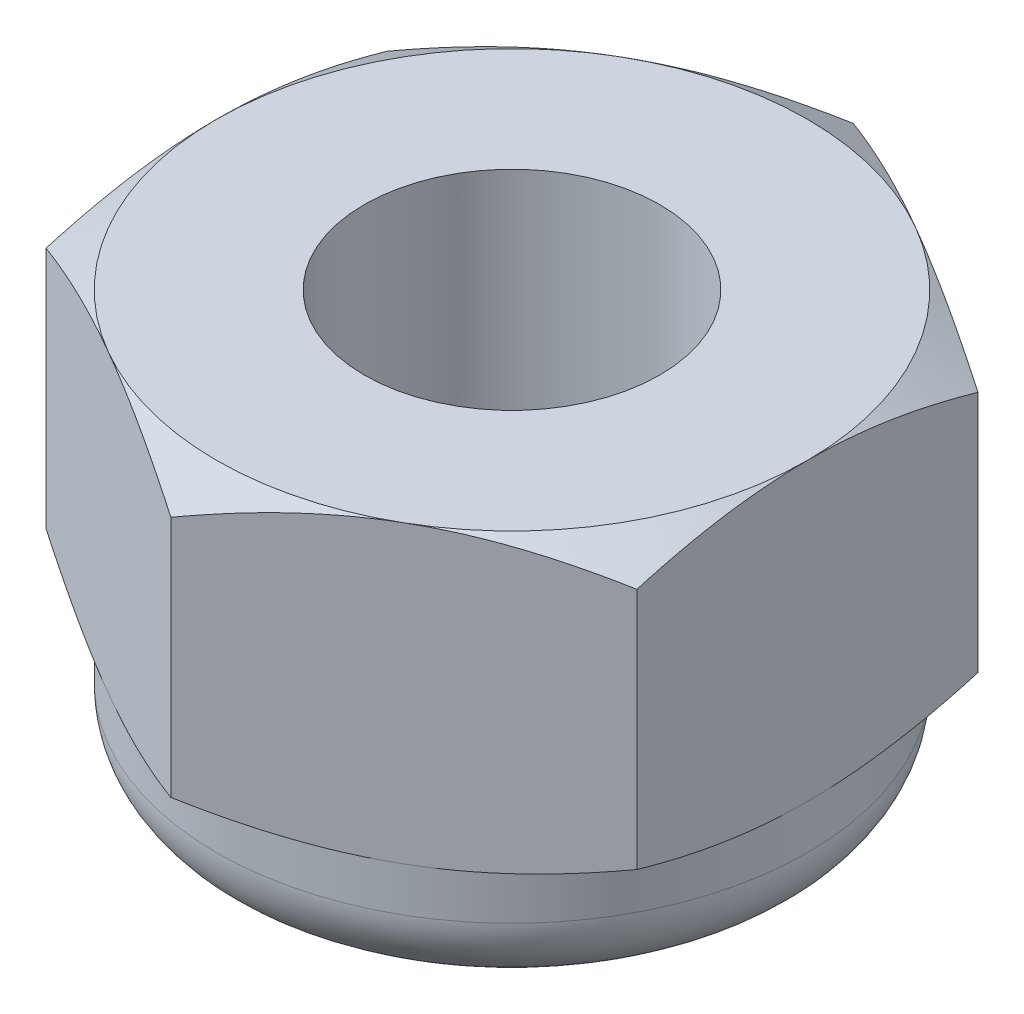
from build123d import *

# Parameters (mm, degrees)
SKETCH_1_R      = 1
EXTRUDE_2_DEPTH = 2
SKETCH_3_R      = 2
SKETCH_3_R_2    = 1
EXTRUDE_3_DEPTH = 0.8
FILLET_1_R      = 0.5


with BuildPart() as part:
    # 草图1 → 凸台-拉伸2 (new body)
    with BuildSketch(Plane(origin=(0, 0, 0), x_dir=(1, 0, 0), z_dir=(0, 1, 0))):
        Polygon((2, 1.154700538), (0, 2.309401077), (-2, 1.154700538), (-2, -1.154700538), (0, -2.309401077), (2, -1.154700538), align=None)
        Circle(SKETCH_1_R, mode=Mode.SUBTRACT)
    extrude(amount=EXTRUDE_2_DEPTH)

    # 草图2 → 切除-旋转1 (revolve, cut)
    with BuildSketch(Plane.XY):
        Polygon((3.732050808, 1), (2, 2), (3.732050808, 2), align=None)
        Polygon((2, 0), (3.732050808, 1), (3.732050808, 0), align=None)
    revolve(axis=Axis((0, 1.981363764, 0), (0, 1, 0)), mode=Mode.SUBTRACT)

    # 草图3 → 凸台-拉伸3 (add)
    with BuildSketch(Plane.XZ):
        Circle(SKETCH_3_R)
        Circle(SKETCH_3_R_2, mode=Mode.SUBTRACT)
    extrude(amount=EXTRUDE_3_DEPTH)

    # 圆角1
    fillet_1_edges = [part.edges().sort_by_distance(p)[0] for p in [
        (-2, -0.8, 0),
    ]]
    fillet(fillet_1_edges, radius=FILLET_1_R)


solid = part.part
